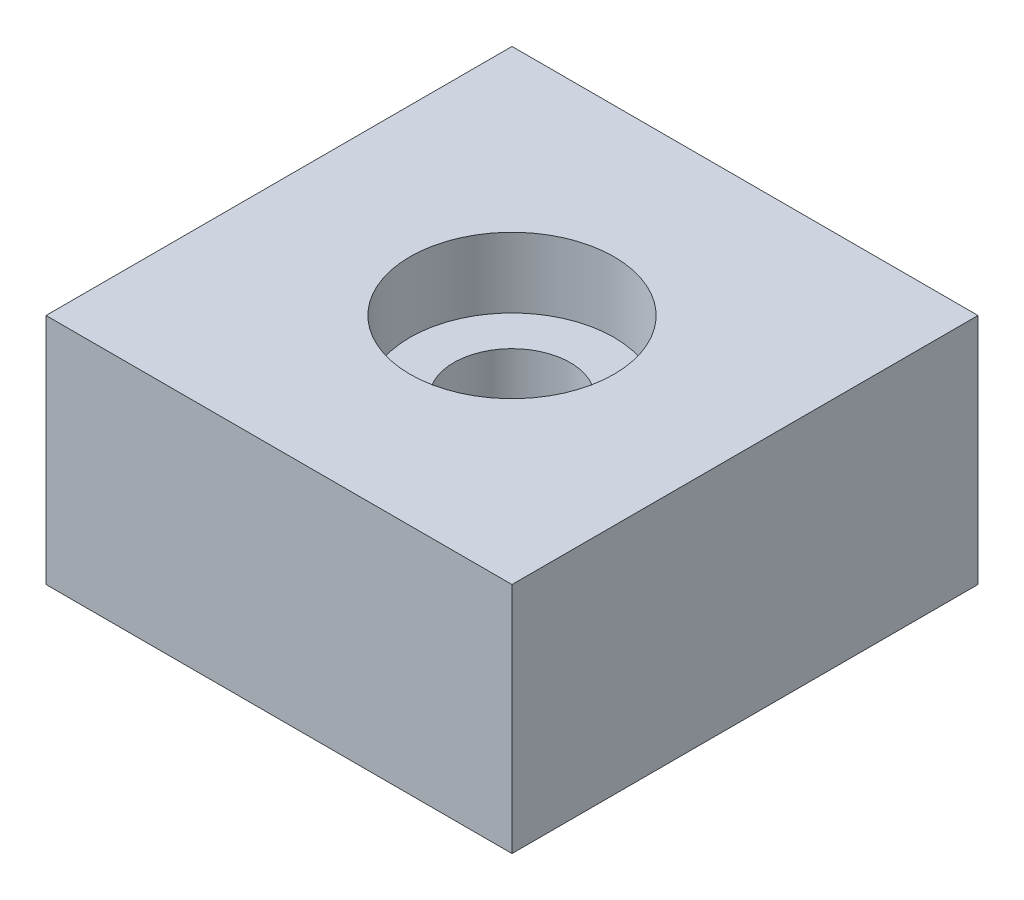
from build123d import *

# Parameters (mm, degrees)
SKETCH2_W                                           = 50.8
SKETCH2_H                                           = 50.8
BOSS_EXTRUDE1_DEPTH                                 = 25.4
CBORE_FOR_00_BINDING_HEAD_MACHINE_SCREW_D           = 12.7
CBORE_FOR_00_BINDING_HEAD_MACHINE_SCREW_CBORE_D     = 22.225
CBORE_FOR_00_BINDING_HEAD_MACHINE_SCREW_CBORE_DEPTH = 7.62


with BuildPart() as part:
    # Sketch2 → Boss-Extrude1 (new body)
    with BuildSketch(Plane(origin=(0, 0, 0), x_dir=(1, 0, 0), z_dir=(0, 1, 0))):
        Rectangle(SKETCH2_W, SKETCH2_H)
    extrude(amount=BOSS_EXTRUDE1_DEPTH)

    # CBORE for #00 Binding Head Machine Screw1 (through all)
    with Locations(Plane(origin=(0, 25.4, 0), x_dir=(1, 0, 0), z_dir=(0, 1, 0))):
        with Locations((0, 0)):
            CounterBoreHole(CBORE_FOR_00_BINDING_HEAD_MACHINE_SCREW_D / 2, CBORE_FOR_00_BINDING_HEAD_MACHINE_SCREW_CBORE_D / 2, CBORE_FOR_00_BINDING_HEAD_MACHINE_SCREW_CBORE_DEPTH)


solid = part.part
